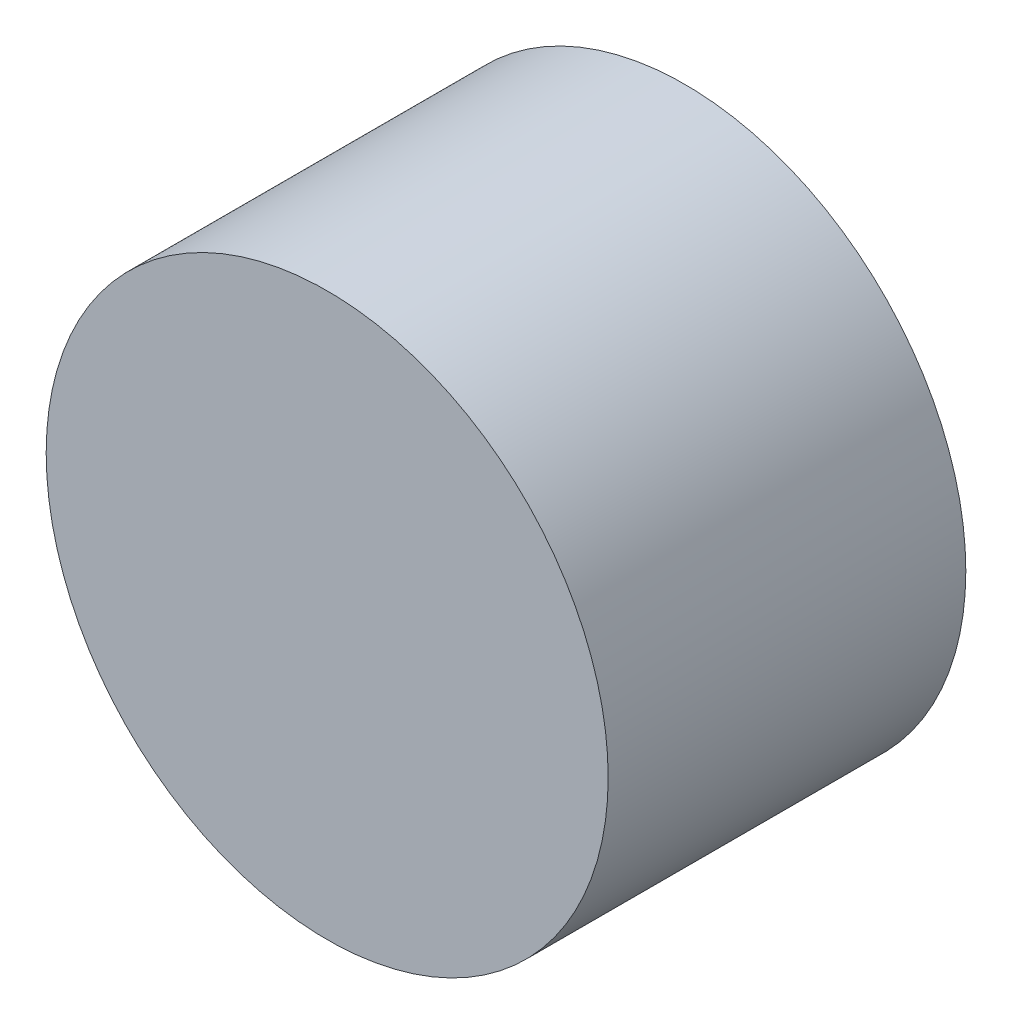
from build123d import *

# Parameters (mm, degrees)
SKETCH1_R           = 1.397
BOSS_EXTRUDE1_DEPTH = 0.889


with BuildPart() as part:
    # Sketch1 → Boss-Extrude1 (new body, symmetric)
    with BuildSketch(Plane.XY):
        Circle(SKETCH1_R)
    extrude(amount=BOSS_EXTRUDE1_DEPTH, both=True)


solid = part.part
